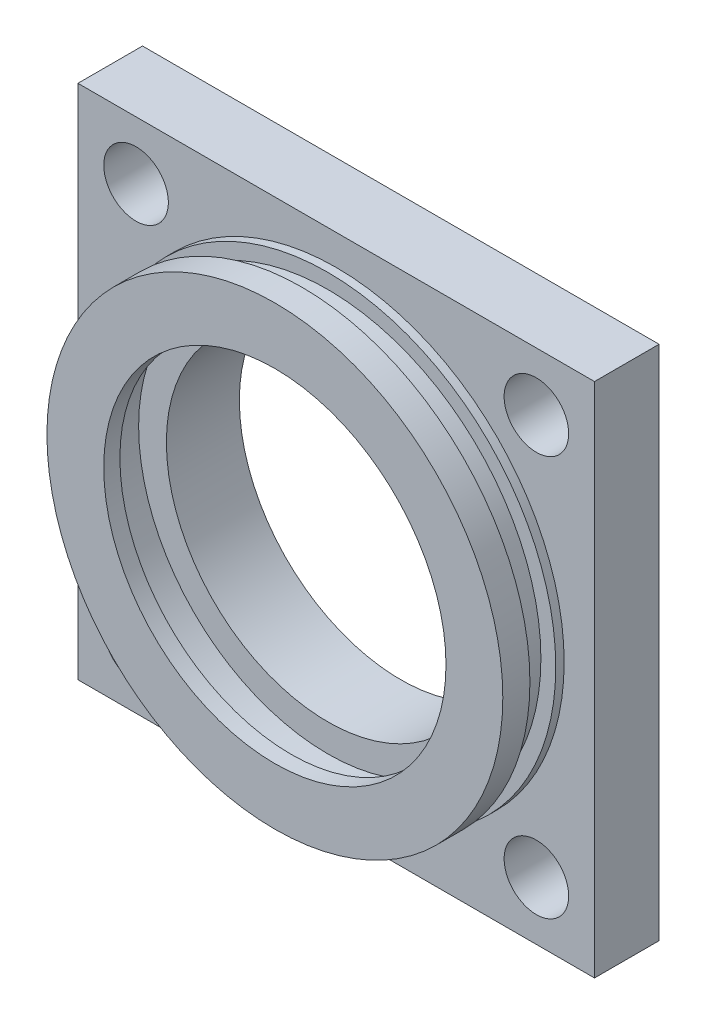
from build123d import *

# Parameters (mm, degrees)
SKETCH2_W                = 80
SKETCH2_H                = 80
BOSS_EXTRUDE1_DEPTH      = 10
SKETCH3_R                = 35.3
BOSS_EXTRUDE2_DEPTH      = 9.5
SKETCH5_R                = 29.3
CUT_EXTRUDE1_DEPTH       = 5.3
SKETCH6_R                = 37.5
SKETCH6_R_2              = 33
CUT_EXTRUDE4_DEPTH       = 4
SKETCH8_R                = 26.5
CUT_EXTRUDE10_DEPTH      = 2.5
SKETCH9_R                = 29.3
CUT_EXTRUDE11_DEPTH      = 5.3
SKETCH10_R               = 25
CUT_EXTRUDE12_DEPTH      = 11.3
SKETCH11_R               = 5
CUT_EXTRUDE13_DEPTH      = 64
CUT_EXTRUDE13_DEPTH_BACK = 36.3


with BuildPart() as part:
    # Sketch2 → Boss-Extrude1 (new body)
    with BuildSketch(Plane.XY):
        with Locations((0, 40)):
            Rectangle(SKETCH2_W, SKETCH2_H)
    extrude(amount=BOSS_EXTRUDE1_DEPTH)

    # Sketch3 → Boss-Extrude2 (add)
    with BuildSketch(Plane.XY.offset(10)):
        with Locations((0, 40)):
            Circle(SKETCH3_R)
    extrude(amount=BOSS_EXTRUDE2_DEPTH)

    # Sketch5 → Cut-Extrude1 (cut)
    with BuildSketch(Plane.XY.offset(11.3)):
        with Locations((0, 40)):
            Circle(SKETCH5_R)
    extrude(amount=CUT_EXTRUDE1_DEPTH, mode=Mode.SUBTRACT)

    # Sketch6 → Cut-Extrude4 (cut)
    with BuildSketch(Plane.XY.offset(11.3)):
        with Locations((0, 40)):
            Circle(SKETCH6_R)
        with Locations((0, 40)):
            Circle(SKETCH6_R_2, mode=Mode.SUBTRACT)
    extrude(amount=CUT_EXTRUDE4_DEPTH, mode=Mode.SUBTRACT)

    # Sketch8 → Cut-Extrude10 (cut)
    with BuildSketch(Plane.XY.offset(19.5)):
        with Locations((0, 40)):
            Circle(SKETCH8_R)
    extrude(amount=-CUT_EXTRUDE10_DEPTH, mode=Mode.SUBTRACT)

    # Sketch9 → Cut-Extrude11 (cut)
    with BuildSketch(Plane.XY.offset(17)):
        with Locations((0, 40)):
            Circle(SKETCH9_R)
    extrude(amount=-CUT_EXTRUDE11_DEPTH, mode=Mode.SUBTRACT)

    # Sketch10 → Cut-Extrude12 (cut)
    with BuildSketch(Plane(origin=(0, 0, 0), x_dir=(-1, 0, 0), z_dir=(0, 0, -1))):
        with Locations((0, 40)):
            Circle(SKETCH10_R)
    extrude(amount=-CUT_EXTRUDE12_DEPTH, mode=Mode.SUBTRACT)

    # Sketch11 → Cut-Extrude13 (cut, two sides)
    with BuildSketch(Plane.XY) as cut_extrude13_sk:
        with Locations((-31, 71)):
            Circle(SKETCH11_R)
        with Locations((31, 71)):
            Circle(SKETCH11_R)
        with Locations((31, 9)):
            Circle(SKETCH11_R)
        with Locations((-31, 9)):
            Circle(SKETCH11_R)
    extrude(amount=CUT_EXTRUDE13_DEPTH, mode=Mode.SUBTRACT)
    extrude(cut_extrude13_sk.sketch, amount=-CUT_EXTRUDE13_DEPTH_BACK, mode=Mode.SUBTRACT)


solid = part.part
